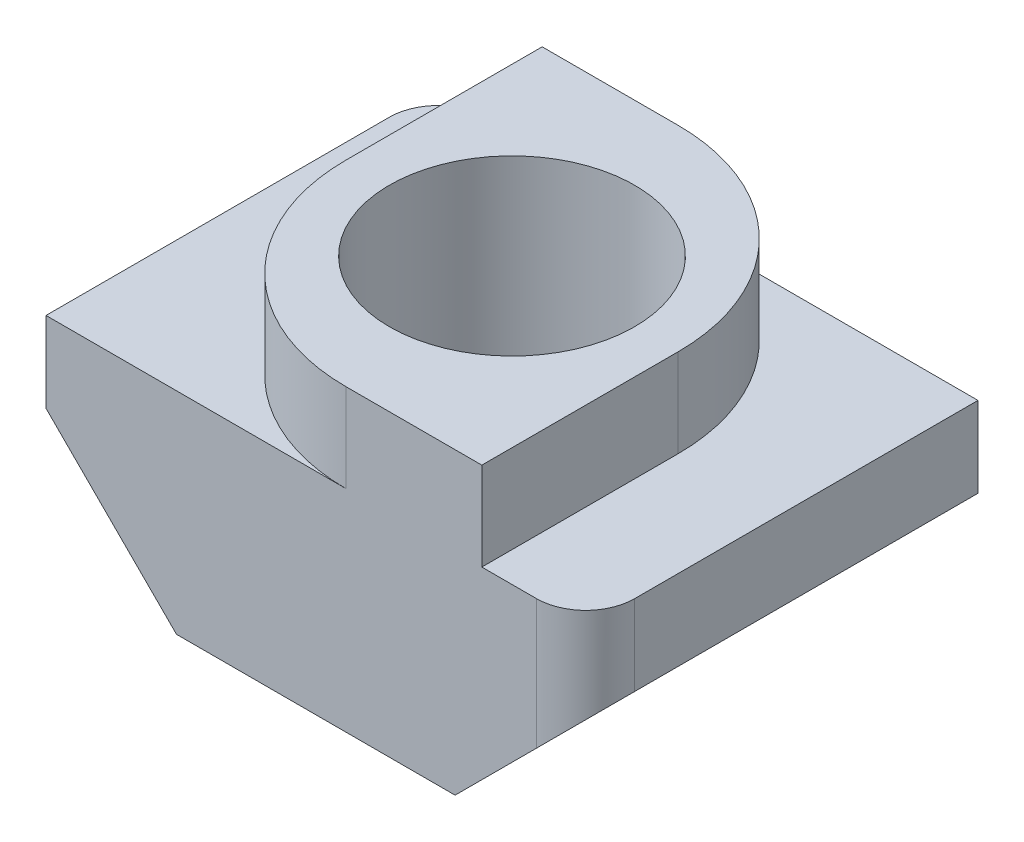
from build123d import *

# Parameters (mm, degrees)
SKETCH1_W           = 11
SKETCH1_H           = 8
SKETCH1_R           = 2.5
BOSS_EXTRUDE1_DEPTH = 4.3
CUT_EXTRUDE1_DEPTH  = 9
SKETCH3_W           = 6.77
SKETCH3_H           = 8
SKETCH3_R           = 2.5
BOSS_EXTRUDE2_DEPTH = 1.8
FILLET1_R           = 4
FILLET2_R           = 1


with BuildPart() as part:
    # Sketch1 → Boss-Extrude1 (new body)
    with BuildSketch(Plane(origin=(0, 0, 0), x_dir=(1, 0, 0), z_dir=(0, 1, 0))):
        Rectangle(SKETCH1_W, SKETCH1_H)
        Circle(SKETCH1_R, mode=Mode.SUBTRACT)
    extrude(amount=BOSS_EXTRUDE1_DEPTH)

    # Sketch2 → Cut-Extrude1 (cut, through all)
    with BuildSketch(Plane.XY.offset(4)):
        Polygon((-5.5, 2.66), (-2.84, 0), (-5.5, 0), align=None)
        Polygon((5.5, 2.66), (5.5, 0), (2.84, 0), align=None)
    extrude(amount=-CUT_EXTRUDE1_DEPTH, mode=Mode.SUBTRACT)

    # Sketch3 → Boss-Extrude2 (add)
    with BuildSketch(Plane(origin=(0, 4.3, 0), x_dir=(1, 0, 0), z_dir=(0, 1, 0))):
        Rectangle(SKETCH3_W, SKETCH3_H)
        Circle(SKETCH3_R, mode=Mode.SUBTRACT)
    extrude(amount=BOSS_EXTRUDE2_DEPTH)

    # Fillet1
    fillet1_edges = [part.edges().sort_by_distance(p)[0] for p in [
        (3.385, 5.2, -4),
        (-3.385, 5.2, 4),
    ]]
    fillet(fillet1_edges, radius=FILLET1_R)

    # Fillet2
    fillet2_edges = [part.edges().sort_by_distance(p)[0] for p in [
        (5.5, 3.48, 4),
        (-5.5, 3.48, -4),
    ]]
    fillet(fillet2_edges, radius=FILLET2_R)


solid = part.part
